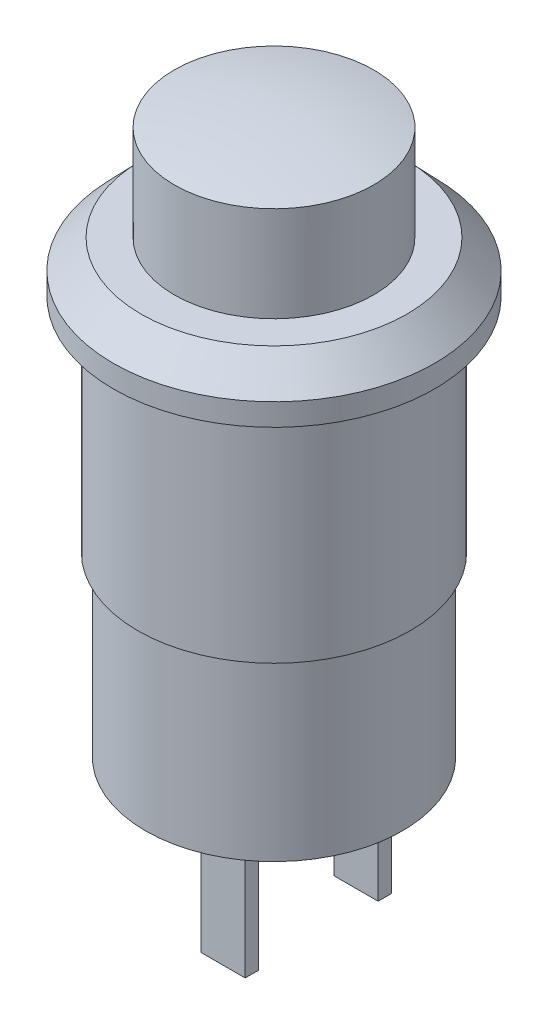
from build123d import *

# Parameters (mm, degrees)
SKETCH2_W           = 2
SKETCH2_H           = 0.6
BOSS_EXTRUDE1_DEPTH = 6


with BuildPart() as part:
    # Sketch1 → Revolve1 (revolve)
    with BuildSketch(Plane.XY):
        with BuildLine():
            Line((-4.5, 6.6), (-4.5, 2.3))
            Line((-4.5, 2.3), (-6, 2.3))
            Line((-6, 2.3), (-7.25, 1))
            Line((-7.25, 1), (-7.25, 0))
            Line((-7.25, 0), (-6.15, 0))
            Line((-6.15, 0), (-6.15, -10))
            Line((-6.15, -10), (-5.8, -10))
            Line((-5.8, -10), (-5.8, -18))
            Line((-5.8, -18), (0, -18))
            Line((0, -18), (0, 7.1))
            ThreePointArc((0, 7.1), (-2.263846285, 6.974616561), (-4.5, 6.6))
        make_face()
    revolve(axis=Axis((0, 17.963306775, 0), (0, -1, 0)))

    # Sketch2 → Boss-Extrude1 (add)
    with BuildSketch(Plane.XZ.offset(18)):
        with Locations((1, 3)):
            Rectangle(SKETCH2_W, SKETCH2_H)
        with Locations((1, -3)):
            Rectangle(SKETCH2_W, SKETCH2_H)
    extrude(amount=BOSS_EXTRUDE1_DEPTH)


solid = part.part
